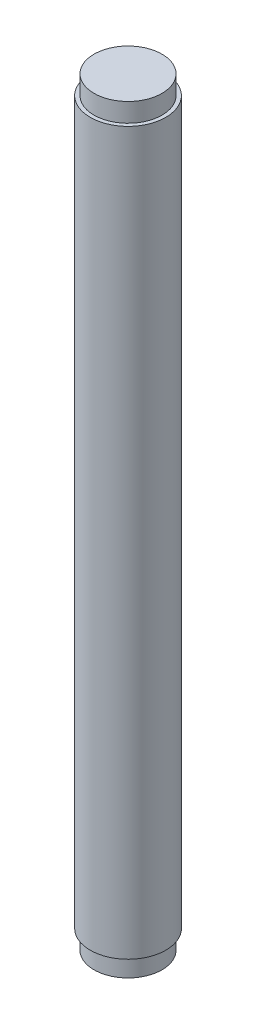
from build123d import *

# Parameters (mm, degrees)
SKETCH1_R           = 5
BOSS_EXTRUDE1_DEPTH = 100.5
SKETCH24_R          = 5
SKETCH24_R_2        = 4.5
CUT_EXTRUDE3_DEPTH  = 2.5
SKETCH25_R          = 5
SKETCH25_R_2        = 4.5
CUT_EXTRUDE4_DEPTH  = 2.5


with BuildPart() as part:
    # Sketch1 → Boss-Extrude1 (new body)
    with BuildSketch(Plane(origin=(0, 0, 0), x_dir=(1, 0, 0), z_dir=(0, 1, 0))):
        Circle(SKETCH1_R)
    extrude(amount=BOSS_EXTRUDE1_DEPTH)

    # Sketch24 → Cut-Extrude3 (cut)
    with BuildSketch(Plane(origin=(0, 0, 0), x_dir=(-1, 0, 0), z_dir=(0, -1, 0))):
        Circle(SKETCH24_R)
        Circle(SKETCH24_R_2, mode=Mode.SUBTRACT)
    extrude(amount=-CUT_EXTRUDE3_DEPTH, mode=Mode.SUBTRACT)

    # Sketch25 → Cut-Extrude4 (cut)
    with BuildSketch(Plane(origin=(0, 100.5, 0), x_dir=(1, 0, 0), z_dir=(0, 1, 0))):
        Circle(SKETCH25_R)
        Circle(SKETCH25_R_2, mode=Mode.SUBTRACT)
    extrude(amount=-CUT_EXTRUDE4_DEPTH, mode=Mode.SUBTRACT)


solid = part.part
